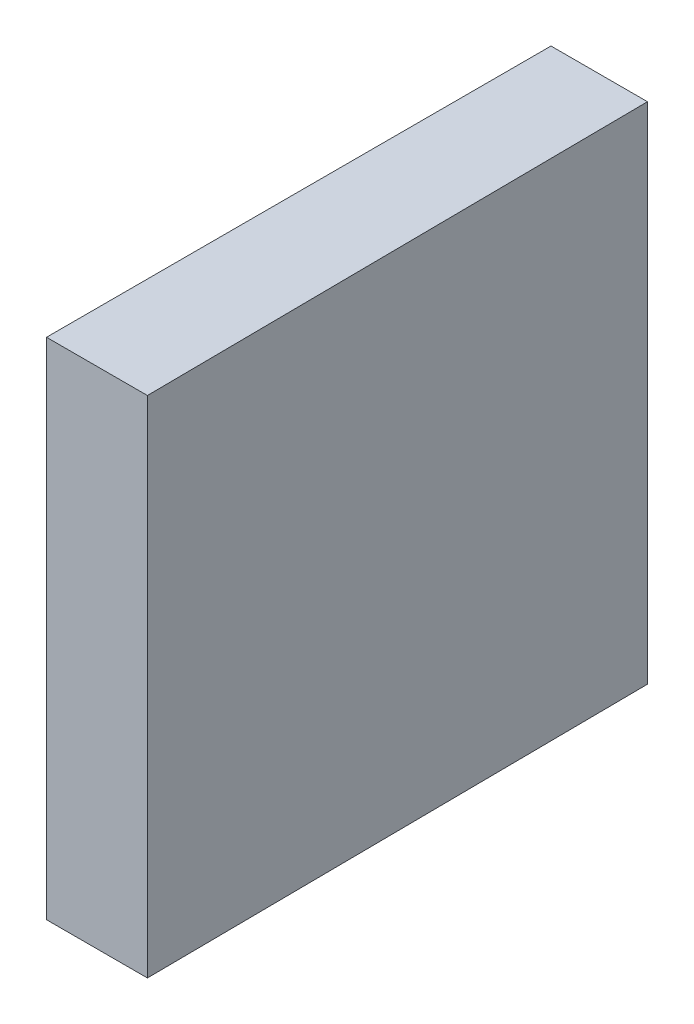
from build123d import *

# Parameters (mm, degrees)
EXTRUDE_1_DEPTH = 25


with BuildPart() as part:
    # 草图1 → 凸台-拉伸1 (new body)
    with BuildSketch(Plane(origin=(0, 0, 0), x_dir=(1, 0, 0), z_dir=(0, 1, 0))):
        Polygon((0, 12.5), (0, -12.5), (5, -12.5), (4.781828305, 12.5), align=None)
    extrude(amount=EXTRUDE_1_DEPTH)


solid = part.part
